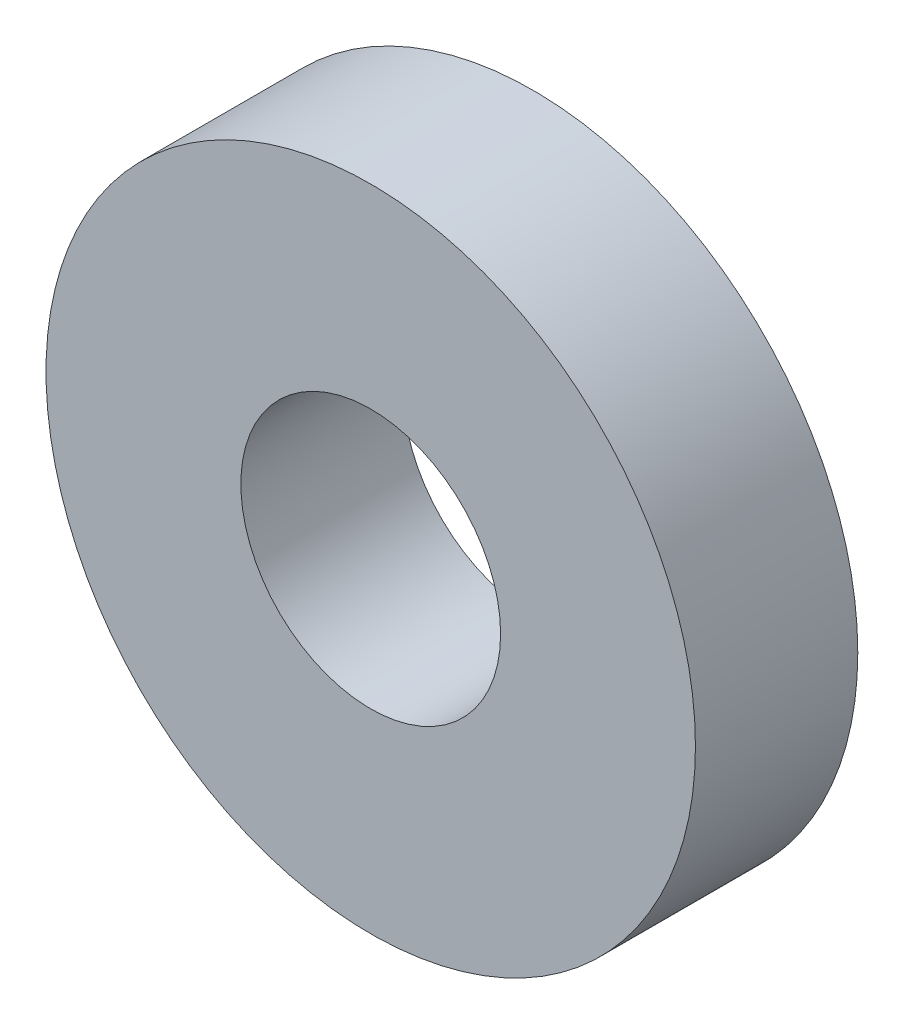
from build123d import *

# Parameters (mm, degrees)
SKETCH_1_R      = 10
SKETCH_1_R_2    = 4
EXTRUDE_1_DEPTH = 5


with BuildPart() as part:
    # 草图1 → 凸台-拉伸1 (new body)
    with BuildSketch(Plane.XY):
        Circle(SKETCH_1_R)
        Circle(SKETCH_1_R_2, mode=Mode.SUBTRACT)
    extrude(amount=EXTRUDE_1_DEPTH)


solid = part.part
